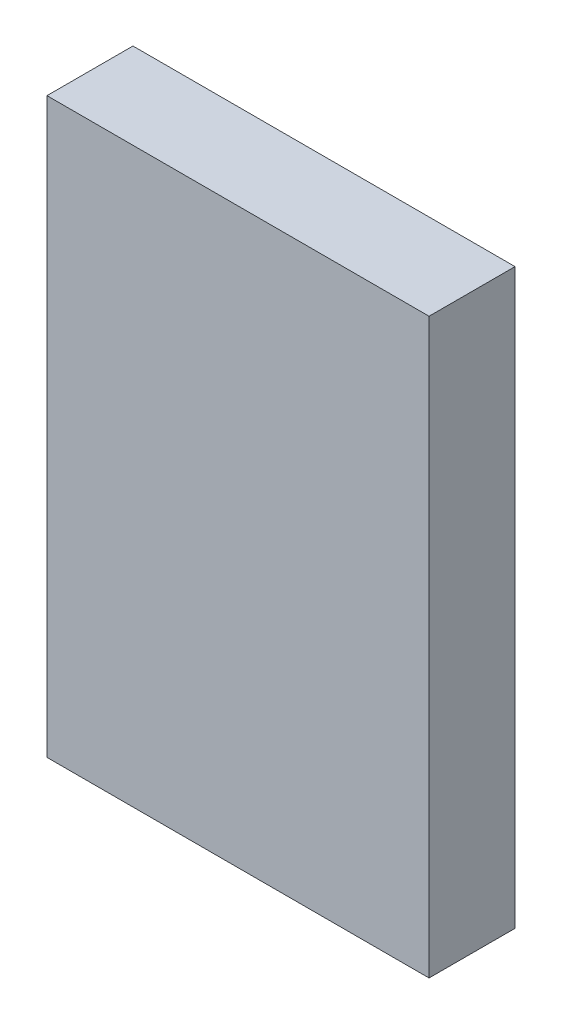
from build123d import *

# Parameters (mm, degrees)
SKETCH1_W           = 80
SKETCH1_H           = 120
BOSS_EXTRUDE1_DEPTH = 18


with BuildPart() as part:
    # Sketch1 → Boss-Extrude1 (new body)
    with BuildSketch(Plane.XY):
        Rectangle(SKETCH1_W, SKETCH1_H)
    extrude(amount=BOSS_EXTRUDE1_DEPTH)


solid = part.part
